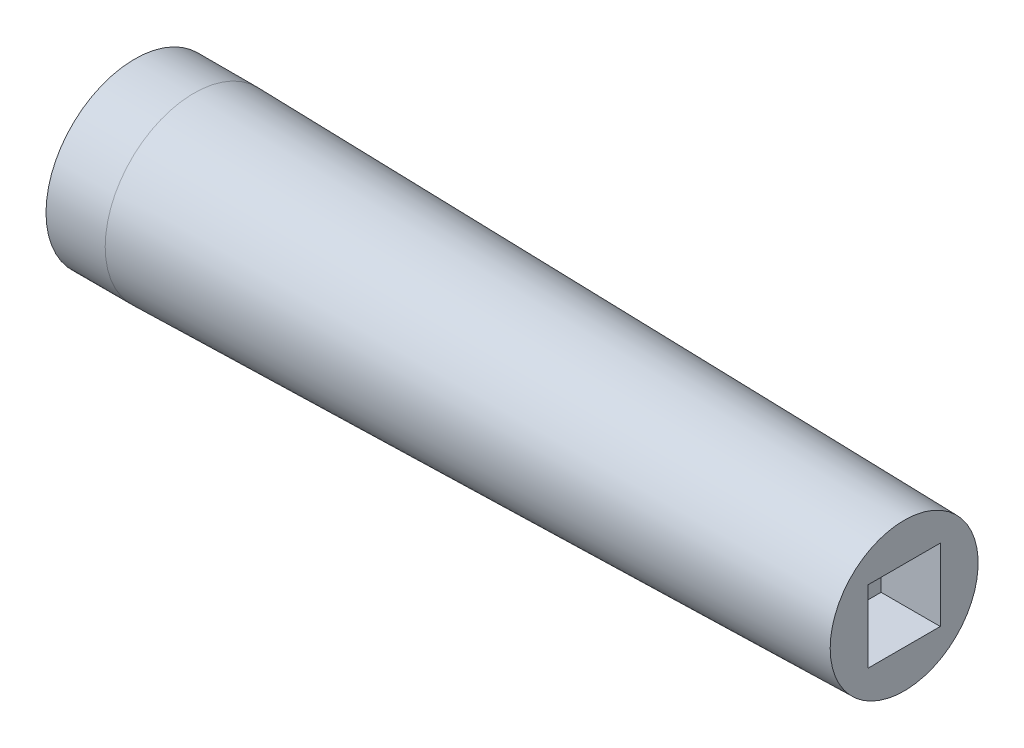
from build123d import *

# Parameters (mm, degrees)
SKETCH2_W          = 15.494
SKETCH2_H          = 15.494
CUT_EXTRUDE1_DEPTH = 12.7


with BuildPart() as part:
    # Sketch1 → Revolve1 (revolve)
    with BuildSketch(Plane.XY):
        Polygon((0, 0), (165.1, 0), (165.1, 15.875), (12.7, 19.05), (0, 19.05), align=None)
    revolve(axis=Axis((0, 0, 0), (1, 0, 0)))

    # Sketch2 → Cut-Extrude1 (cut)
    with BuildSketch(Plane(origin=(165.1, 0, 0), x_dir=(0, 0, -1), z_dir=(1, 0, 0))):
        Rectangle(SKETCH2_W, SKETCH2_H)
    extrude(amount=-CUT_EXTRUDE1_DEPTH, mode=Mode.SUBTRACT)


solid = part.part
